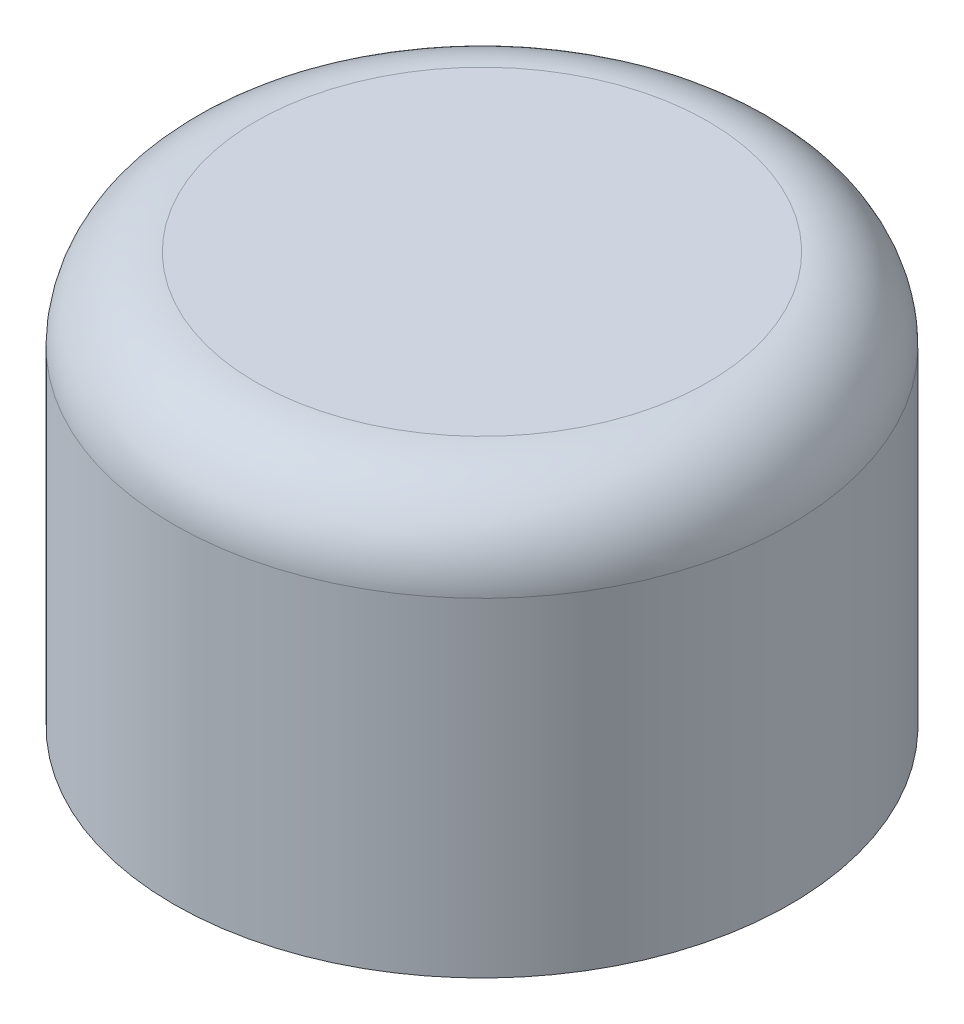
from build123d import *

# Parameters (mm, degrees)
SKETCH2_R                        = 15
BOSS_EXTRUDE1_DEPTH              = 20
TAP_DRILL_FOR_M18X2_5_TAP1_D     = 15.5
TAP_DRILL_FOR_M18X2_5_TAP1_DEPTH = 15
TAP_DRILL_FOR_M18X2_5_TAP1_TIP   = 4.656669797
FILLET1_R                        = 4


with BuildPart() as part:
    # Sketch2 → Boss-Extrude1 (new body)
    with BuildSketch(Plane(origin=(0, 0, 0), x_dir=(1, 0, 0), z_dir=(0, 1, 0))):
        Circle(SKETCH2_R)
    extrude(amount=BOSS_EXTRUDE1_DEPTH)

    # Tap Drill for M18x2.5 Tap1
    with Locations(Plane(origin=(0, 0, 0), x_dir=(-1, 0, 0), z_dir=(0, -1, 0))):
        with Locations((0, 0)):
            Hole(TAP_DRILL_FOR_M18X2_5_TAP1_D / 2, depth=TAP_DRILL_FOR_M18X2_5_TAP1_DEPTH)
            with Locations((0, 0, -(TAP_DRILL_FOR_M18X2_5_TAP1_DEPTH + TAP_DRILL_FOR_M18X2_5_TAP1_TIP / 2))):  # 118° drill point
                Cone(0, TAP_DRILL_FOR_M18X2_5_TAP1_D / 2, TAP_DRILL_FOR_M18X2_5_TAP1_TIP, mode=Mode.SUBTRACT)

    # Fillet1
    fillet1_edges = [part.edges().sort_by_distance(p)[0] for p in [
        (-15, 20, 0),
    ]]
    fillet(fillet1_edges, radius=FILLET1_R)


solid = part.part
